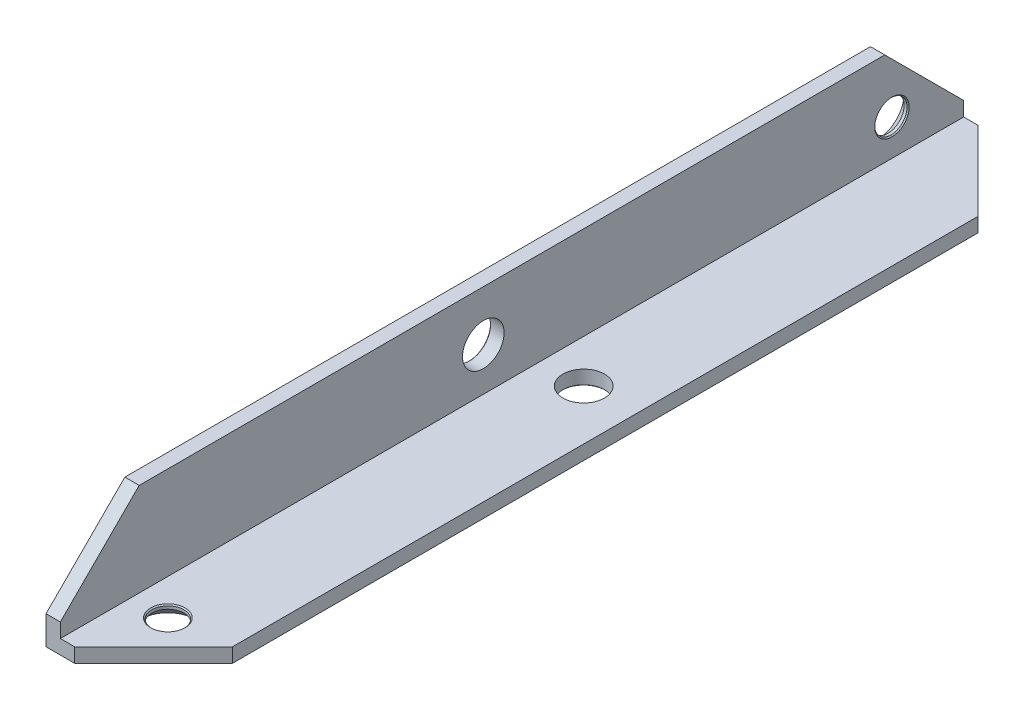
from build123d import *

# Parameters (mm, degrees)
EXTRUDE_1_DEPTH             = 126
CHAMFER_1_SIZE              = 11
HOLE_WIZARD_M51_D           = 5.8
HOLE_WIZARD_M51_DEPTH       = 3
HOLE_WIZARD_M51_CSINK_D     = 6
HOLE_WIZARD_M51_CSINK_ANGLE = 90
HOLE_WIZARD_M51_TIP         = 1.742495795
HOLE_WIZARD_M52_D           = 5.8
HOLE_WIZARD_M52_DEPTH       = 3
HOLE_WIZARD_M52_CSINK_D     = 6
HOLE_WIZARD_M52_CSINK_ANGLE = 90
HOLE_WIZARD_M52_TIP         = 1.742495795


with BuildPart() as part:
    # Эскиз1 → Бобышка-Вытянуть1 (new body)
    with BuildSketch(Plane.XY):
        Polygon((0, 0), (0, 15), (2, 15), (2, 2), (15, 2), (15, 0), align=None)
    extrude(amount=EXTRUDE_1_DEPTH)

    # Фаска1
    chamfer_1_edges = [part.edges().sort_by_distance(p)[0] for p in [
        (1, 15, 126),
        (1, 15, 0),
        (15, 1, 126),
        (15, 1, 0),
    ]]
    chamfer(chamfer_1_edges, length=CHAMFER_1_SIZE)

    # Эскиз2 → Зенковка для винта с потайной головкой M41 (revolve, cut)
    with BuildSketch(Plane(origin=(7, 0, 116), x_dir=(0, 0, -1), z_dir=(1, 0, 0))):
        Polygon((0, 0), (0, 2), (2.4, 2), (2.25, 1.85), (2.25, 1.45), (3.7, 0), align=None)
    revolve(axis=Axis((7, -6.35, 116), (0, 1, 0)), mode=Mode.SUBTRACT)

    # Эскиз4 → Зенковка для винта с потайной головкой M42 (revolve, cut)
    with BuildSketch(Plane(origin=(0, 7, 10), x_dir=(0, 0, 1), z_dir=(0, 1, 0))):
        Polygon((0, 0), (0, 2), (2.4, 2), (2.25, 1.85), (2.25, 1.45), (3.7, 0), align=None)
    revolve(axis=Axis((-6.35, 7, 10), (1, 0, 0)), mode=Mode.SUBTRACT)

    # Отверстие с зазором M51
    with Locations(Plane.XZ):
        with Locations((8, 59)):
            CounterSinkHole(HOLE_WIZARD_M51_D / 2, HOLE_WIZARD_M51_CSINK_D / 2, depth=HOLE_WIZARD_M51_DEPTH, counter_sink_angle=HOLE_WIZARD_M51_CSINK_ANGLE)
            with Locations((0, 0, -(HOLE_WIZARD_M51_DEPTH + HOLE_WIZARD_M51_TIP / 2))):  # 118° drill point
                Cone(0, HOLE_WIZARD_M51_D / 2, HOLE_WIZARD_M51_TIP, mode=Mode.SUBTRACT)

    # Отверстие с зазором M52
    with Locations(Plane.ZY):
        with Locations((67, 8)):
            CounterSinkHole(HOLE_WIZARD_M52_D / 2, HOLE_WIZARD_M52_CSINK_D / 2, depth=HOLE_WIZARD_M52_DEPTH, counter_sink_angle=HOLE_WIZARD_M52_CSINK_ANGLE)
            with Locations((0, 0, -(HOLE_WIZARD_M52_DEPTH + HOLE_WIZARD_M52_TIP / 2))):  # 118° drill point
                Cone(0, HOLE_WIZARD_M52_D / 2, HOLE_WIZARD_M52_TIP, mode=Mode.SUBTRACT)


solid = part.part
